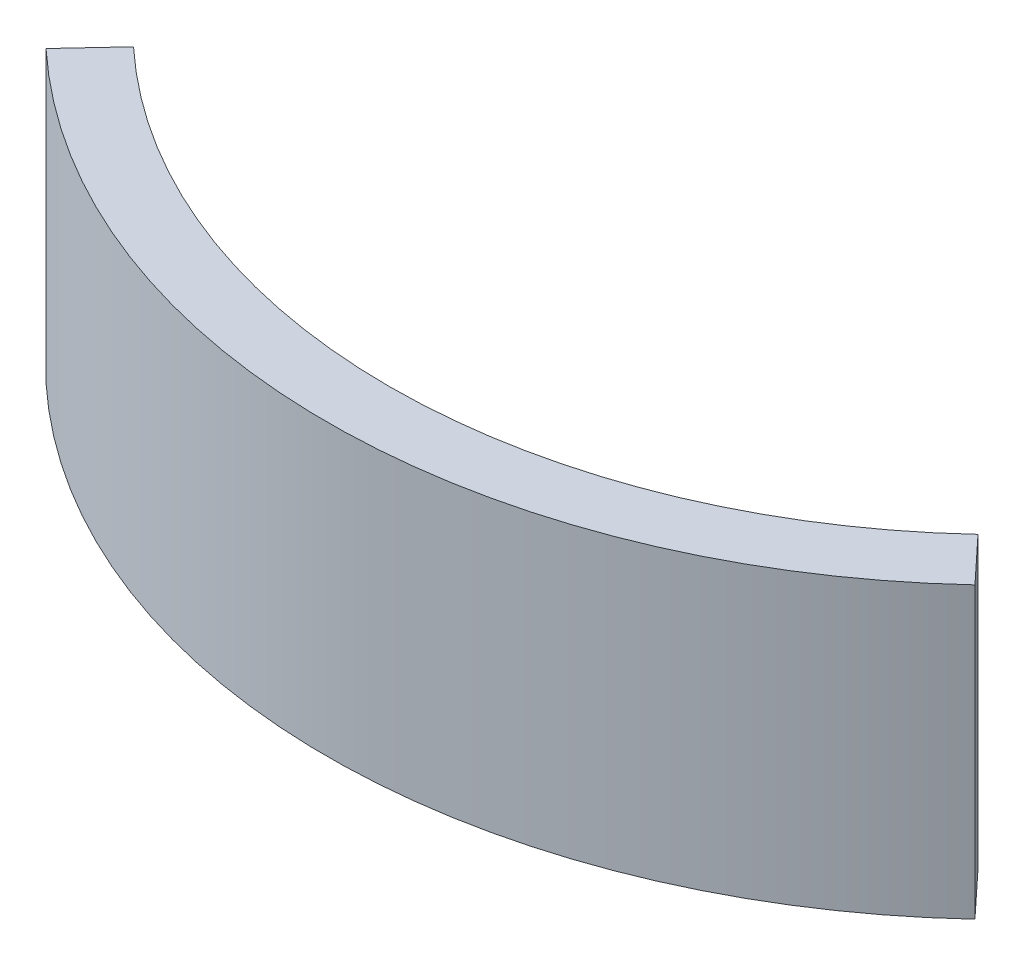
from build123d import *

# Parameters (mm, degrees)
BOSS_EXTRUDE1_DEPTH = 6.08


with BuildPart() as part:
    # Sketch1 → Boss-Extrude1 (new body)
    with BuildSketch(Plane(origin=(0, 0, 0), x_dir=(1, 0, 0), z_dir=(0, 1, 0))):
        with BuildLine():
            Line((9.752576549, 3.841642067), (8.865978681, 4.792401879))
            ThreePointArc((8.865978681, 4.792401879), (0, 1.3), (-8.865978681, 4.792401879))
            Line((-8.865978681, 4.792401879), (-9.752576549, 3.841642067))
            ThreePointArc((-9.752576549, 3.841642067), (0, 0), (9.752576549, 3.841642067))
        make_face()
    extrude(amount=BOSS_EXTRUDE1_DEPTH)


solid = part.part
